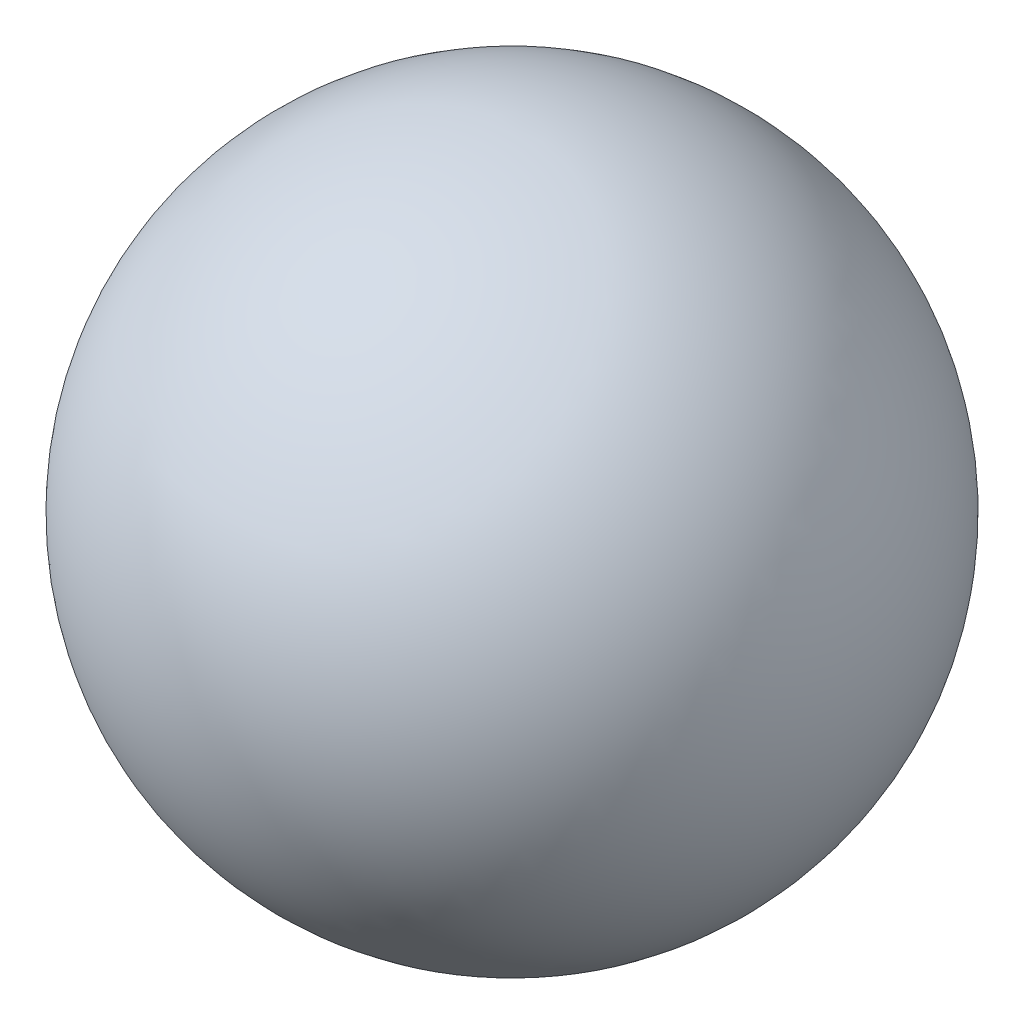
from build123d import *

# Parameters (mm, degrees)
SKETCH7_W          = 1.5875
SKETCH7_H          = 7.62
CUT_EXTRUDE1_DEPTH = 0.0254


with BuildPart() as part:
    # Sketch1 → Complete_Ball (revolve)
    with BuildSketch(Plane.XY):
        with BuildLine():
            Line((0, 12.7), (0, -12.7))
            ThreePointArc((0, -12.7), (12.7, 0), (0, 12.7))
        make_face()
    revolve(axis=Axis((0, 13.965019531, 0), (0, -1, 0)))

    # Sketch7 → Ball_w_concentric_hole (revolve, cut)
    with BuildSketch(Plane.XY):
        with Locations((0.79375, -8.89)):
            Rectangle(SKETCH7_W, SKETCH7_H)
    revolve(axis=Axis((0, -6.726898043, 0), (0, 1, 0)), mode=Mode.SUBTRACT)

    # Sketch9 → Cut-Extrude1 (cut)
    with BuildSketch(Plane.XZ.offset(5.08)):
        with BuildLine():
            add(Edge.make_bspline(
                [(0.308076994, -0.030373732), (0.324538713, -0.034024291), (0.356530602, -0.041118827), (0.402477662, -0.054290859), (0.445054282, -0.069285046), (0.484732885, -0.085294373), (0.521280558, -0.103036208), (0.554555606, -0.122564651), (0.584482781, -0.143830699), (0.602480105, -0.159466562), (0.611281283, -0.167112921)],
                knots=[0, 0, 0, 0, 1.202298385, 2.336560135, 3.406084711, 4.420247637, 5.386399354, 6.300522109, 7.168909389, 8, 8, 8, 8], degree=3))
            add(Edge.make_bspline(
                [(0.611281283, -0.167112921), (0.622417749, -0.178075677), (0.644400951, -0.199715976), (0.67281694, -0.235522748), (0.696753104, -0.273154409), (0.716536823, -0.312521351), (0.731766785, -0.353857034), (0.742939599, -0.39692676), (0.749363419, -0.441811935), (0.750162969, -0.472278831), (0.750568408, -0.487728101)],
                knots=[0, 0, 0, 0, 1.040892545, 2.054704896, 3.038886078, 4.009403739, 4.985637774, 5.96968326, 6.970459233, 8, 8, 8, 8], degree=3))
            add(Edge.make_bspline(
                [(0.750568408, -0.487728101), (0.749580677, -0.511480749), (0.747596123, -0.559204719), (0.728910303, -0.629570582), (0.700367842, -0.698612498), (0.660350876, -0.764646818), (0.611443791, -0.826373993), (0.551760396, -0.878883273), (0.484387528, -0.923101532), (0.421448289, -0.952346751), (0.365407997, -0.970620061), (0.317719104, -0.98275638), (0.264926091, -0.993624769), (0.20667372, -1.001054176), (0.143434911, -1.008194794), (0.07484539, -1.01250787), (0.001081213, -1.015688606), (-0.049903845, -1.015893946), (-0.076236566, -1.016)],
                knots=[0, 0, 0, 0, 1.028770293, 2.067011775, 3.138033473, 4.261901228, 5.406207792, 6.541562624, 7.694800496, 8.892876887, 9.539626609, 10.250184141, 11.027081459, 11.876550478, 12.796927842, 13.788050093, 14.85757392, 16, 16, 16, 16], degree=3))
            Line((-0.076236566, -1.016), (-0.988822024, -1.016))
            Line((-0.988822024, -1.016), (-0.988822024, -0.961644049))
            Line((-0.988822024, -0.961644049), (-0.917904495, -0.961644049))
            add(Edge.make_bspline(
                [(-0.917904495, -0.961644049), (-0.908402664, -0.961432941), (-0.890024832, -0.961024629), (-0.863622385, -0.956950597), (-0.839065748, -0.951375967), (-0.816950335, -0.942204208), (-0.796626646, -0.931084721), (-0.778261022, -0.917590019), (-0.762272466, -0.901062238), (-0.753405479, -0.88858522), (-0.74889146, -0.882233402)],
                knots=[0, 0, 0, 0, 1.166786496, 2.256723755, 3.277842578, 4.25348796, 5.187934752, 6.120436128, 7.043148905, 8, 8, 8, 8], degree=3))
            add(Edge.make_bspline(
                [(-0.74889146, -0.882233402), (-0.746190352, -0.877347431), (-0.740363736, -0.866807802), (-0.734346678, -0.84805755), (-0.728780995, -0.826107168), (-0.724762233, -0.800356427), (-0.721378545, -0.77103352), (-0.718963551, -0.738021693), (-0.71713277, -0.701491854), (-0.717073307, -0.675994887), (-0.717042269, -0.662686318)],
                knots=[0, 0, 0, 0, 0.597321695, 1.288494999, 2.101981578, 3.025155317, 4.079375286, 5.266669335, 6.573292293, 8, 8, 8, 8], degree=3))
            Line((-0.717042269, -0.662686318), (-0.717042269, 0.587500555))
            add(Edge.make_bspline(
                [(-0.717042269, 0.587500555), (-0.717020857, 0.602227129), (-0.716980065, 0.63028246), (-0.719451119, 0.670192763), (-0.721936908, 0.705972397), (-0.726817478, 0.737387607), (-0.732121451, 0.764688921), (-0.738568219, 0.7877891), (-0.747095316, 0.806473529), (-0.754139821, 0.816751719), (-0.757384577, 0.821485937)],
                knots=[0, 0, 0, 0, 1.467983741, 2.79662948, 3.986363477, 5.042318655, 5.964098798, 6.759038926, 7.428403245, 8, 8, 8, 8], degree=3))
            add(Edge.make_bspline(
                [(-0.757384577, 0.821485937), (-0.766968382, 0.831548203), (-0.786306937, 0.851852213), (-0.824785442, 0.872201997), (-0.869332734, 0.884203522), (-0.901116145, 0.885678948), (-0.917904495, 0.886458285)],
                knots=[0, 0, 0, 0, 0.927123666, 1.870784184, 2.875324672, 4, 4, 4, 4], degree=3))
            Line((-0.917904495, 0.886458285), (-0.988822024, 0.886458285))
            Line((-0.988822024, 0.886458285), (-0.988822024, 0.940814236))
            Line((-0.988822024, 0.940814236), (-0.162866363, 0.940814236))
            add(Edge.make_bspline(
                [(-0.162866363, 0.940814236), (-0.126188539, 0.940513422), (-0.056725795, 0.939943722), (0.041752121, 0.932910915), (0.129010541, 0.922793404), (0.182730464, 0.91105738), (0.207858209, 0.905567799)],
                knots=[0, 0, 0, 0, 1.179035714, 2.232931189, 3.173445281, 4, 4, 4, 4], degree=3))
            add(Edge.make_bspline(
                [(0.207858209, 0.905567799), (0.225058291, 0.900995857), (0.258662627, 0.892063511), (0.306862604, 0.874872481), (0.35200904, 0.855362596), (0.394161004, 0.833417302), (0.432870067, 0.808543943), (0.468965178, 0.781808256), (0.501653259, 0.752055301), (0.530912052, 0.719772753), (0.556715696, 0.685606681), (0.580062927, 0.650467371), (0.598866319, 0.613375247), (0.614986078, 0.57548153), (0.626598012, 0.536066061), (0.635806285, 0.495707281), (0.640869134, 0.453863359), (0.641524814, 0.425577459), (0.641856506, 0.41126837)],
                knots=[0, 0, 0, 0, 1.197163213, 2.33893505, 3.43955965, 4.504702612, 5.532566955, 6.532694419, 7.523891994, 8.501634608, 9.459882266, 10.403051993, 11.336018195, 12.25408421, 13.170072591, 14.09679423, 15.037218469, 16, 16, 16, 16], degree=3))
            add(Edge.make_bspline(
                [(0.641856506, 0.41126837), (0.640988305, 0.386966428), (0.639277347, 0.339074706), (0.622358228, 0.269582217), (0.595666689, 0.204017494), (0.565112824, 0.152992911), (0.535110113, 0.115449663), (0.510556404, 0.08830852), (0.482805357, 0.063927102), (0.452810586, 0.041062695), (0.420086682, 0.020541755), (0.38522035, 0.001209477), (0.347651311, -0.015759261), (0.321445222, -0.025436955), (0.308076994, -0.030373732)],
                knots=[0, 0, 0, 0, 1.471082931, 2.899056279, 4.307818116, 5.751614296, 6.484736272, 7.219614112, 7.967209451, 8.720692231, 9.503935749, 10.306636219, 11.136182697, 12, 12, 12, 12], degree=3))
        make_face()
        with BuildLine():
            add(Edge.make_bspline(
                [(-0.445262514, 0.037995862), (-0.426327321, 0.034656251), (-0.386080053, 0.027557818), (-0.321529386, 0.021144961), (-0.249825238, 0.017428628), (-0.199675095, 0.016991416), (-0.173482759, 0.016763069)],
                knots=[0, 0, 0, 0, 0.844887106, 1.795830451, 2.848809897, 4, 4, 4, 4], degree=3))
            add(Edge.make_bspline(
                [(-0.173482759, 0.016763069), (-0.156495387, 0.016960654), (-0.123639547, 0.017342808), (-0.076026849, 0.019288173), (-0.031719973, 0.023285242), (0.00930446, 0.028009349), (0.047066576, 0.035115731), (0.08167708, 0.042721005), (0.112945821, 0.052723303), (0.149614447, 0.066940798), (0.19007552, 0.088916151), (0.23035913, 0.122823227), (0.261457989, 0.163456789), (0.282889969, 0.210155805), (0.296731598, 0.260777518), (0.308199203, 0.31345399), (0.314500353, 0.368508228), (0.315309667, 0.405874992), (0.3157208, 0.424857357)],
                knots=[0, 0, 0, 0, 1.091830023, 2.111744693, 3.061402081, 3.95056914, 4.764258185, 5.530001833, 6.226288629, 6.871621508, 8.056545267, 9.166642, 10.231067328, 11.317616446, 12.446050905, 13.598649409, 14.780110772, 16, 16, 16, 16], degree=3))
            add(Edge.make_bspline(
                [(0.3157208, 0.424857357), (0.315274183, 0.439594324), (0.314394441, 0.468623136), (0.308579089, 0.511424009), (0.297616446, 0.552413229), (0.283341565, 0.591889551), (0.264856225, 0.629856323), (0.24190265, 0.6657694), (0.214734501, 0.700054926), (0.1840394, 0.732629931), (0.149194905, 0.76249929), (0.110236379, 0.788477557), (0.067684677, 0.810609885), (0.021216663, 0.82849277), (-0.028831328, 0.842453754), (-0.082873755, 0.85205292), (-0.140507573, 0.858047973), (-0.180261974, 0.858862407), (-0.200660735, 0.85928031)],
                knots=[0, 0, 0, 0, 0.932104058, 1.836054539, 2.724128921, 3.610577454, 4.48739039, 5.388899496, 6.300486582, 7.250348221, 8.215526472, 9.196272454, 10.205292906, 11.242666987, 12.339557976, 13.48617357, 14.710106481, 16, 16, 16, 16], degree=3))
            add(Edge.make_bspline(
                [(-0.200660735, 0.85928031), (-0.222755045, 0.858845399), (-0.265893392, 0.857996252), (-0.32895856, 0.852174222), (-0.388604371, 0.84167089), (-0.426645356, 0.831254772), (-0.445262514, 0.826157152)],
                knots=[0, 0, 0, 0, 1.070391011, 2.089899941, 3.065202048, 4, 4, 4, 4], degree=3))
            Line((-0.445262514, 0.826157152), (-0.445262514, 0.037995862))
        make_face(mode=Mode.SUBTRACT)
        with BuildLine():
            add(Edge.make_bspline(
                [(-0.445262514, -0.894973078), (-0.417443506, -0.901131169), (-0.362095565, -0.913383138), (-0.278646345, -0.925338098), (-0.195705669, -0.932903229), (-0.140658937, -0.933945707), (-0.113181626, -0.934466073)],
                knots=[0, 0, 0, 0, 1.019899824, 2.029164851, 3.016231376, 4, 4, 4, 4], degree=3))
            add(Edge.make_bspline(
                [(-0.113181626, -0.934466073), (-0.091929976, -0.934252226), (-0.050751607, -0.933837863), (0.009069282, -0.927437289), (0.065096664, -0.918561989), (0.117145516, -0.905172654), (0.165579696, -0.88891324), (0.209737927, -0.867987195), (0.25019028, -0.843565692), (0.286693969, -0.815673306), (0.318630006, -0.784579101), (0.347205512, -0.752213582), (0.370951573, -0.71762533), (0.390803655, -0.681461485), (0.405596026, -0.643095371), (0.41676876, -0.603336191), (0.423256869, -0.561547228), (0.424035612, -0.533188423), (0.424432702, -0.518727979)],
                knots=[0, 0, 0, 0, 1.335369974, 2.58748639, 3.778398001, 4.898614871, 5.962444548, 6.985554789, 7.963871145, 8.928614683, 9.866425566, 10.762210136, 11.638554271, 12.498661649, 13.349744001, 14.217688406, 15.091181162, 16, 16, 16, 16], degree=3))
            add(Edge.make_bspline(
                [(0.424432702, -0.518727979), (0.4235265, -0.499567493), (0.421710444, -0.461169303), (0.409685349, -0.404035632), (0.388218739, -0.348651871), (0.359964971, -0.294377764), (0.322780244, -0.243092717), (0.275077564, -0.197879287), (0.218738662, -0.157870999), (0.15288954, -0.124748012), (0.078754411, -0.097458162), (-0.003925713, -0.078132811), (-0.094744496, -0.066773569), (-0.158019387, -0.065455602), (-0.19089365, -0.064770857)],
                knots=[0, 0, 0, 0, 0.80426076, 1.611762754, 2.437163379, 3.29025987, 4.174362993, 5.081949637, 6.03643416, 7.064744133, 8.166225842, 9.344998398, 10.620602567, 12, 12, 12, 12], degree=3))
            add(Edge.make_bspline(
                [(-0.19089365, -0.064770857), (-0.205191428, -0.064684482), (-0.232799059, -0.0645177), (-0.272567725, -0.065669626), (-0.309100885, -0.066295208), (-0.351293058, -0.06804369), (-0.396516564, -0.070242075), (-0.430284502, -0.075571351), (-0.445262514, -0.077935189)],
                knots=[0, 0, 0, 0, 1.009225997, 1.948718216, 2.808291512, 3.588270035, 4.930259813, 6, 6, 6, 6], degree=3))
            Line((-0.445262514, -0.077935189), (-0.445262514, -0.894973078))
        make_face(mode=Mode.SUBTRACT)
    extrude(amount=-CUT_EXTRUDE1_DEPTH, mode=Mode.SUBTRACT)


solid = part.part
